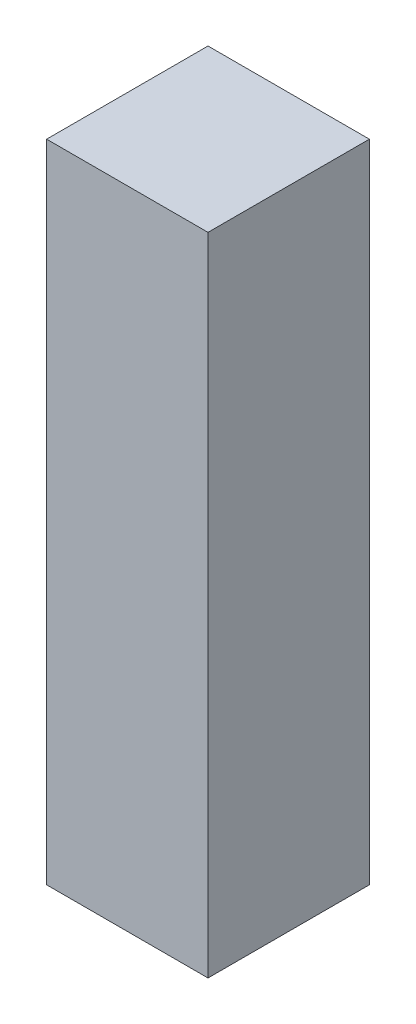
from build123d import *

# Parameters (mm, degrees)
SKETCH2_W           = 3.175
SKETCH2_H           = 12.70508
BOSS_EXTRUDE1_DEPTH = 3.175


with BuildPart() as part:
    # Sketch2 → Boss-Extrude1 (new body)
    with BuildSketch(Plane.XY):
        Rectangle(SKETCH2_W, SKETCH2_H)
    extrude(amount=BOSS_EXTRUDE1_DEPTH)


solid = part.part
